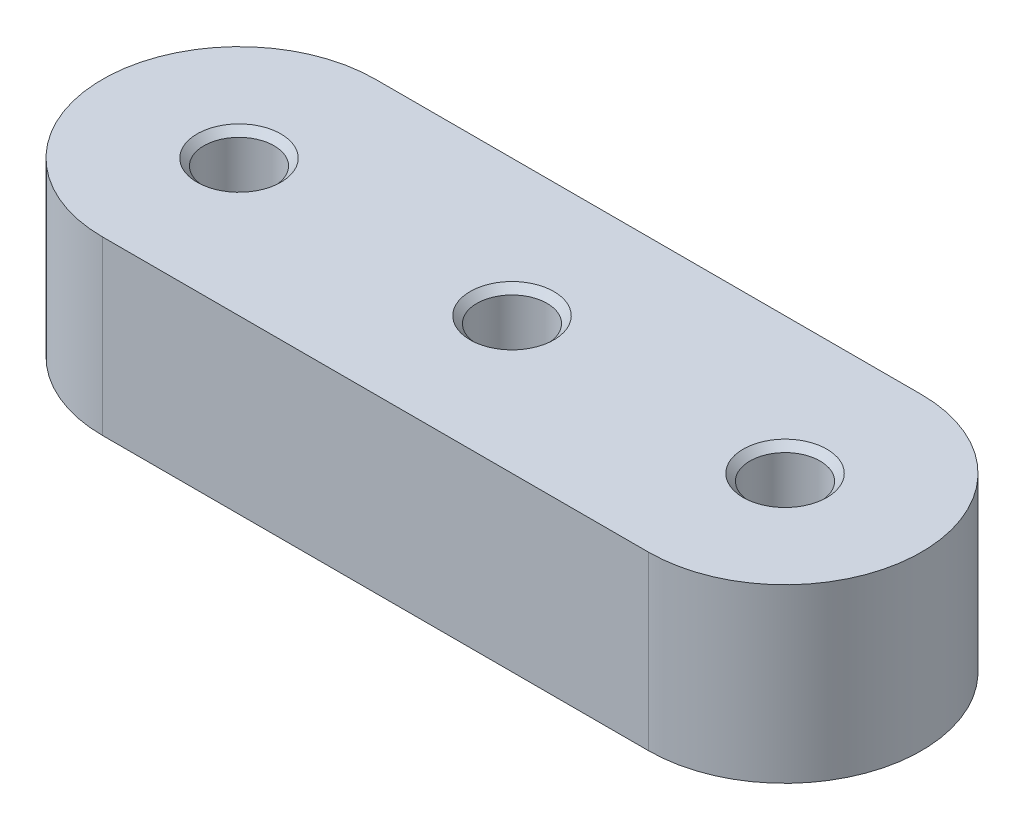
from build123d import *

# Parameters (mm, degrees)
EXTRUDE1_DEPTH                   = 16
F_1_4_CLEARANCE_HOLE1_AT_2_COUNT = 2
F_1_4_CLEARANCE_HOLE1_AT_2_PITCH = 25.4
F_1_4_CLEARANCE_HOLE1_AT_3_COUNT = 2
F_1_4_CLEARANCE_HOLE1_AT_3_PITCH = 25.4


with BuildPart() as part:
    # Sketch1 → Extrude1 (new body)
    with BuildSketch(Plane(origin=(0, 0, 0), x_dir=(1, 0, 0), z_dir=(0, 1, 0))):
        with BuildLine():
            Line((-25.4, 12.7), (25.4, 12.7))
            ThreePointArc((25.4, 12.7), (38.1, 0), (25.4, -12.7))
            Line((25.4, -12.7), (-25.4, -12.7))
            ThreePointArc((-25.4, -12.7), (-38.1, 0), (-25.4, 12.7))
        make_face()
    extrude(amount=-EXTRUDE1_DEPTH)

    # Sketch2 → 1/4 Clearance Hole1 (revolve, cut)
    with BuildSketch(Plane(origin=(0, 0, 0), x_dir=(0, 0, 1), z_dir=(1, 0, 0))):
        Polygon((0, 0), (0, 16), (3.8989, 16), (3.2639, 15.365), (3.2639, 0.635), (3.8989, 0), align=None)
    f_1_4_clearance_hole1 = revolve(axis=Axis((0, 6.35, 0), (0, -1, 0)), mode=Mode.SUBTRACT)

    # 1/4 Clearance Hole1 at 2: 1/4 Clearance Hole1 ×2
    with Locations(*[(-i * F_1_4_CLEARANCE_HOLE1_AT_2_PITCH, 0, 0) for i in range(1, F_1_4_CLEARANCE_HOLE1_AT_2_COUNT)]):
        add(f_1_4_clearance_hole1, mode=Mode.SUBTRACT)

    # 1/4 Clearance Hole1 at 3: 1/4 Clearance Hole1 ×2
    with Locations(*[(i * F_1_4_CLEARANCE_HOLE1_AT_3_PITCH, 0, 0) for i in range(1, F_1_4_CLEARANCE_HOLE1_AT_3_COUNT)]):
        add(f_1_4_clearance_hole1, mode=Mode.SUBTRACT)


solid = part.part
